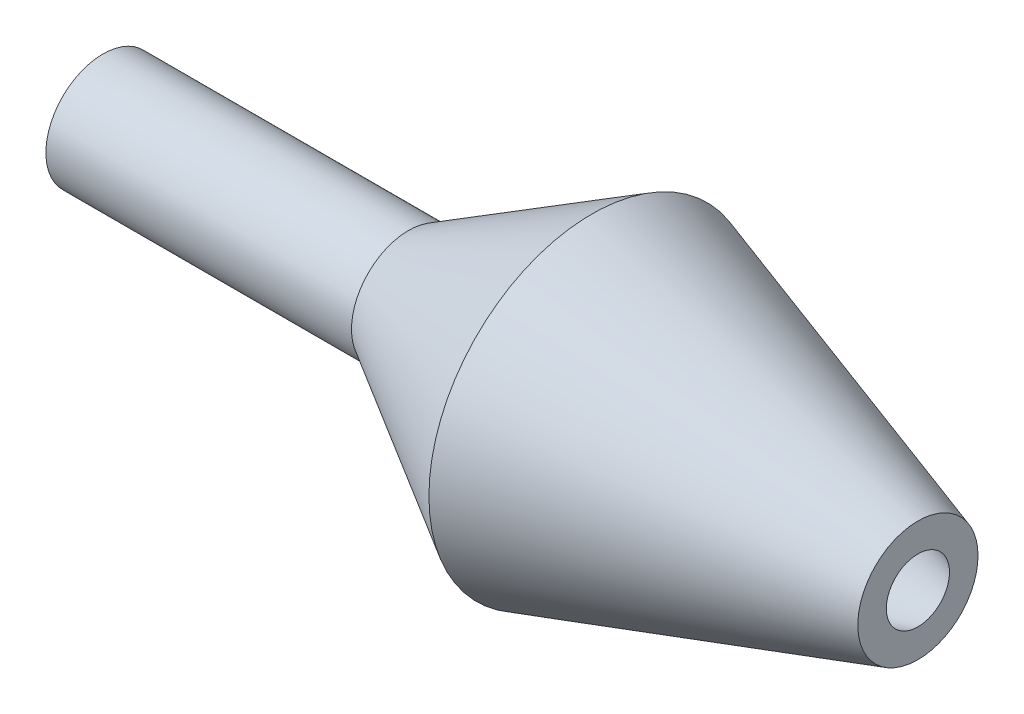
from build123d import *


with BuildPart() as part:
    # Sketch1 → Revolve1 (revolve)
    with BuildSketch(Plane(origin=(0, 0, 0), x_dir=(1, 0, 0), z_dir=(0, 1, 0))):
        Polygon((-40, 1.4), (-25, 1.4), (-16, 6.6), (0, 1.55), (0, 2.95), (-16, 8), (-25, 2.8), (-40, 2.8), align=None)
    revolve(axis=Axis((0, 0, 0), (-1, 0, 0)))


solid = part.part
